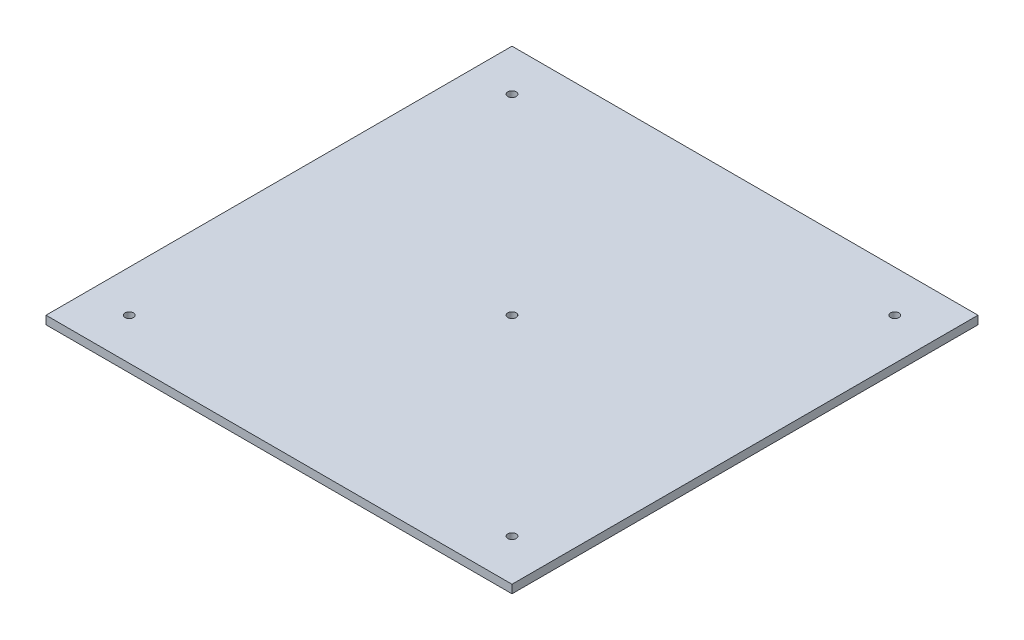
from build123d import *

# Parameters (mm, degrees)
SKETCH1_W                                  = 112
SKETCH1_H                                  = 112
BOSS_EXTRUDE1_DEPTH                        = 2
SKETCH2_R                                  = 1
CUT_EXTRUDE1_DEPTH                         = 2
MIRROR1_AT_THE_SECOND_PLANE_COPY_1_SKETC_R = 1
MIRROR1_AT_THE_SECOND_PLANE_COPY_1_DEPTH   = 2


with BuildPart() as part:
    # Sketch1 → Boss-Extrude1 (new body)
    with BuildSketch(Plane(origin=(0, 0, 0), x_dir=(1, 0, 0), z_dir=(0, 1, 0))):
        Rectangle(SKETCH1_W, SKETCH1_H)
    extrude(amount=BOSS_EXTRUDE1_DEPTH)

    # Sketch2 → Cut-Extrude1 (cut)
    with BuildSketch(Plane(origin=(0, 2, 0), x_dir=(1, 0, 0), z_dir=(0, 1, 0))):
        with Locations((-46, -46)):
            Circle(SKETCH2_R)
        Circle(SKETCH2_R)
    cut_extrude1 = extrude(amount=-CUT_EXTRUDE1_DEPTH, mode=Mode.SUBTRACT)

    # Mirror1: Cut-Extrude1 across plane
    add(cut_extrude1.mirror(Plane(origin=(0, 0, 0), x_dir=(0, 0, 1), z_dir=(1, 0, 0))), mode=Mode.SUBTRACT)

    # Mirror1 at the second plane: Cut-Extrude1 across plane
    add(cut_extrude1.mirror(Plane.XY), mode=Mode.SUBTRACT)

    # Mirror1 at the second plane copy 1 sketc → Mirror1 at the second plane copy 1 (cut)
    with BuildSketch(Plane(origin=(0, 2, 0), x_dir=(-1, 0, 0), z_dir=(0, 1, 0))):
        with Locations((-46, -46)):
            Circle(MIRROR1_AT_THE_SECOND_PLANE_COPY_1_SKETC_R)
        Circle(MIRROR1_AT_THE_SECOND_PLANE_COPY_1_SKETC_R)
    extrude(amount=-MIRROR1_AT_THE_SECOND_PLANE_COPY_1_DEPTH, mode=Mode.SUBTRACT)


solid = part.part
